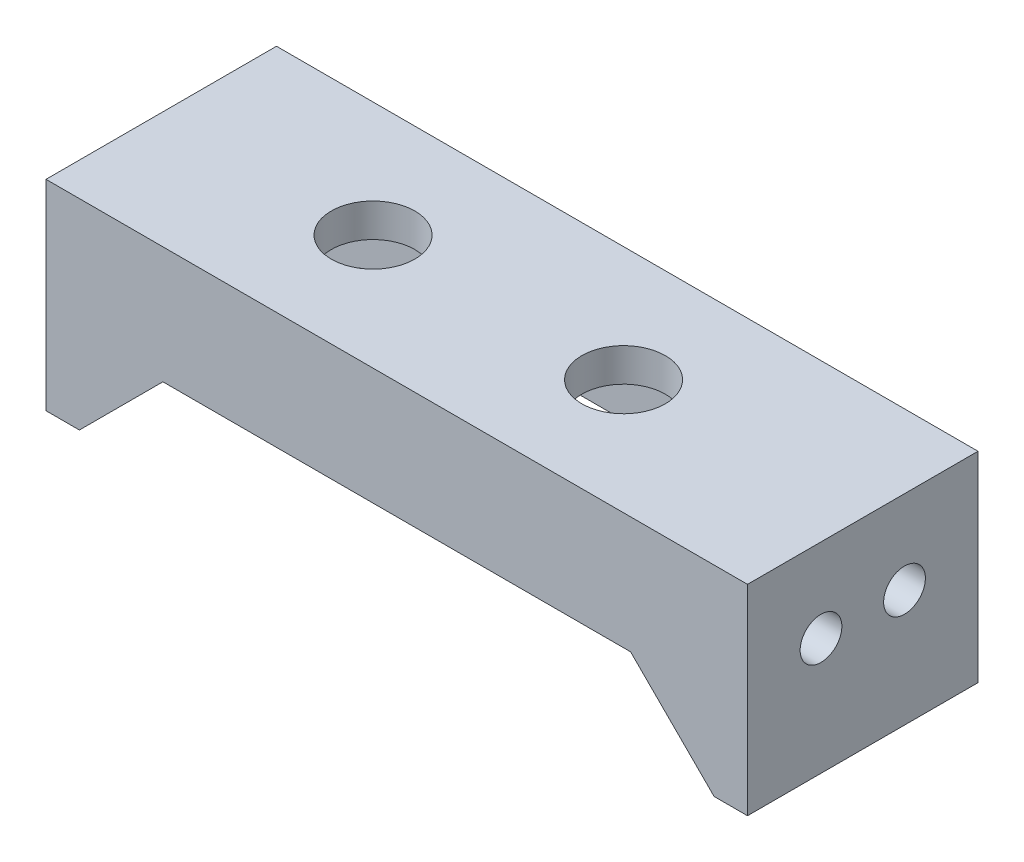
from build123d import *

# Parameters (mm, degrees)
SKETCH2_W           = 42
SKETCH2_H           = 13.8
BOSS_EXTRUDE1_DEPTH = 2
SKETCH3_W           = 2
SKETCH3_H           = 13.8
BOSS_EXTRUDE2_DEPTH = 10
BOSS_EXTRUDE3_DEPTH = 2
SKETCH5_R           = 2.5
CUT_EXTRUDE1_DEPTH  = 2
SKETCH6_R           = 1.25
CUT_EXTRUDE2_DEPTH  = 2


with BuildPart() as part:
    # Sketch2 → Boss-Extrude1 (new body)
    with BuildSketch(Plane(origin=(0, 0, 0), x_dir=(1, 0, 0), z_dir=(0, 1, 0))):
        Rectangle(SKETCH2_W, SKETCH2_H)
    extrude(amount=BOSS_EXTRUDE1_DEPTH)

    # Sketch3 → Boss-Extrude2 (add)
    with BuildSketch(Plane.XZ):
        with Locations((-20, 0)):
            Rectangle(SKETCH3_W, SKETCH3_H)
        with Locations((20, 0)):
            Rectangle(SKETCH3_W, SKETCH3_H)
    extrude(amount=BOSS_EXTRUDE2_DEPTH)

    # Sketch4 → Boss-Extrude3 (add)
    with BuildSketch(Plane.XY.offset(6.9)):
        Polygon((-19, 0), (19, 0), (19, -10), (14, -5), (-14, -5), (-19, -10), align=None)
    boss_extrude3 = extrude(amount=-BOSS_EXTRUDE3_DEPTH)

    # Mirror1: Boss-Extrude3 across plane
    add(boss_extrude3.mirror(Plane.XY))

    # Sketch5 → Cut-Extrude1 (cut)
    with BuildSketch(Plane.XZ):
        with Locations((-8.319906625, 0)):
            Circle(SKETCH5_R)
        with Locations((6.680093375, 0)):
            Circle(SKETCH5_R)
    extrude(amount=-CUT_EXTRUDE1_DEPTH, mode=Mode.SUBTRACT)

    # Sketch6 → Cut-Extrude2 (cut)
    with BuildSketch(Plane(origin=(-19, 0, 0), x_dir=(0, 0, -1), z_dir=(1, 0, 0))):
        with Locations((-2.5, -3)):
            Circle(SKETCH6_R)
        with Locations((2.5, -3)):
            Circle(SKETCH6_R)
    cut_extrude2 = extrude(amount=-CUT_EXTRUDE2_DEPTH, mode=Mode.SUBTRACT)

    # Mirror2: Cut-Extrude2 across plane
    add(cut_extrude2.mirror(Plane(origin=(0, 0, 0), x_dir=(0, 0, 1), z_dir=(1, 0, 0))), mode=Mode.SUBTRACT)


solid = part.part
